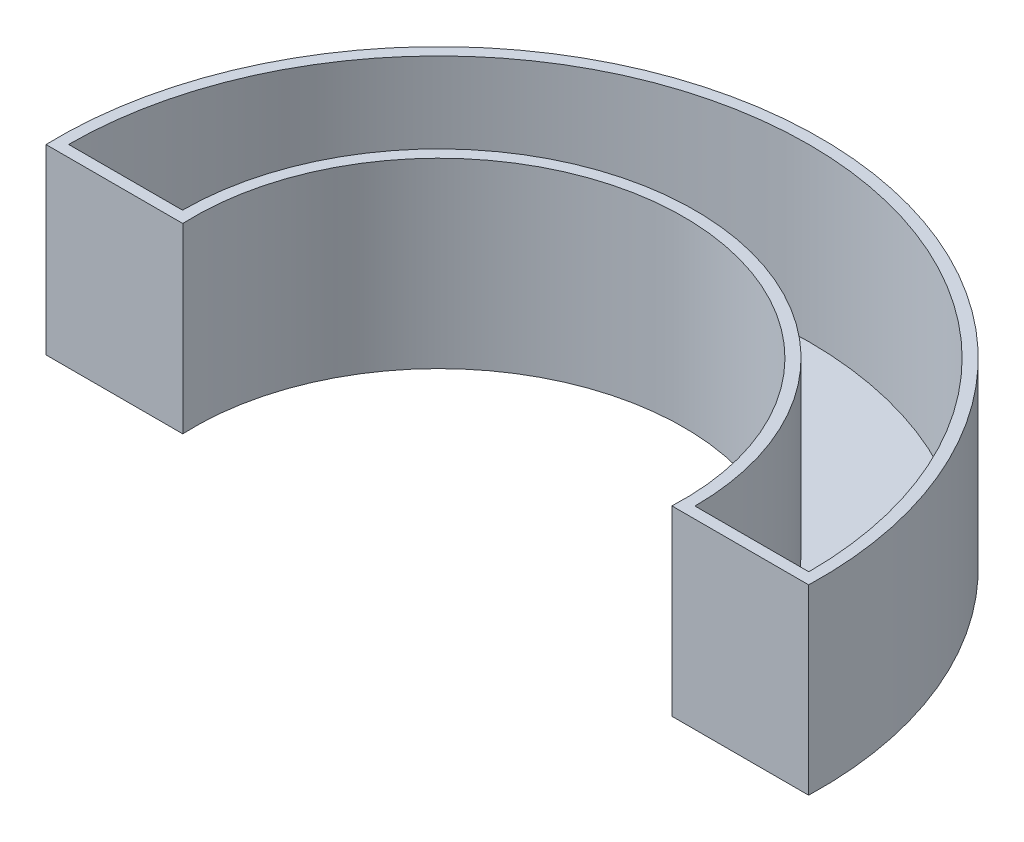
from build123d import *

# Parameters (mm, degrees)
BOSS_EXTRUDE1_DEPTH = 6
BOSS_EXTRUDE2_DEPTH = 0.4


with BuildPart() as part:
    # Sketch3 → Boss-Extrude1 (new body)
    with BuildSketch(Plane(origin=(0, 0, 0), x_dir=(1, 0, 0), z_dir=(0, 1, 0))):
        with BuildLine():
            Line((8.590692638, -0.4), (13.39402852, -0.4))
            ThreePointArc((13.39402852, -0.4), (0, 13.4), (-13.39402852, -0.4))
            Line((-13.39402852, -0.4), (-8.590692638, -0.4))
            ThreePointArc((-8.590692638, -0.4), (0, 8.6), (8.590692638, -0.4))
        make_face()
        with BuildLine():
            Line((9, 0), (13, 0))
            ThreePointArc((13, 0), (0, 13), (-13, 0))
            Line((-13, 0), (-9, 0))
            ThreePointArc((-9, 0), (0, 9), (9, 0))
        make_face(mode=Mode.SUBTRACT)
    extrude(amount=BOSS_EXTRUDE1_DEPTH)

    # Sketch4 → Boss-Extrude2 (add)
    with BuildSketch(Plane.XZ):
        with BuildLine():
            Line((8.590692638, 0.4), (13.39402852, 0.4))
            ThreePointArc((13.39402852, 0.4), (0, -13.4), (-13.39402852, 0.4))
            Line((-13.39402852, 0.4), (-8.590692638, 0.4))
            ThreePointArc((-8.590692638, 0.4), (0, -8.6), (8.590692638, 0.4))
        make_face()
    extrude(amount=BOSS_EXTRUDE2_DEPTH)


solid = part.part
